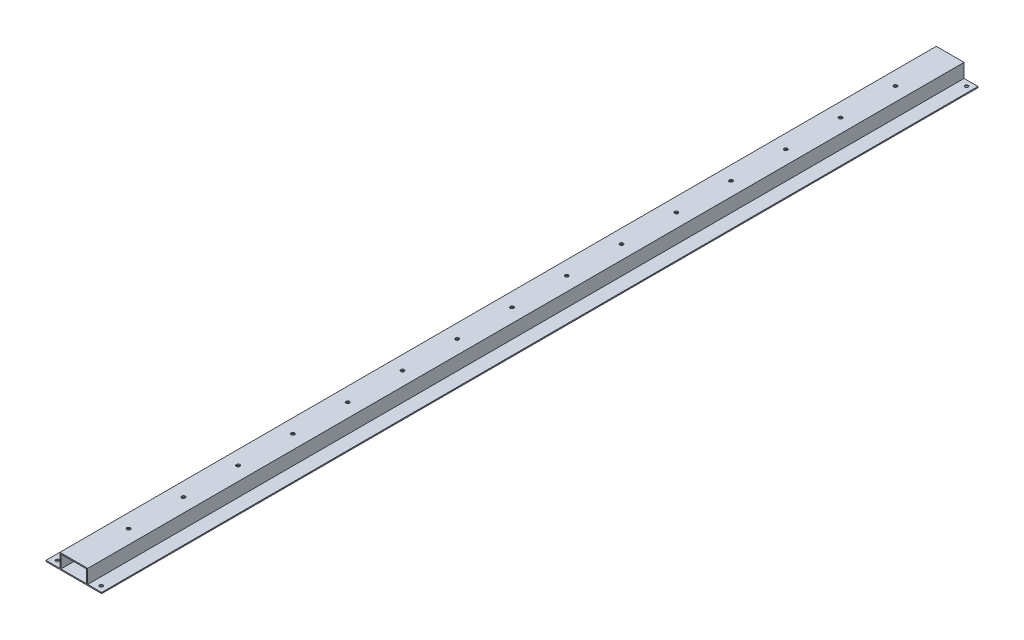
from build123d import *

# Parameters (mm, degrees)
SALIENTE_EXTRUIR1_DEPTH = 400
CROQUIS2_R              = 1.5
CORTAR_EXTRUIR1_DEPTH   = 10
CROQUIS3_R              = 1.5875
CORTAR_EXTRUIR2_DEPTH   = 14.7


with BuildPart() as part:
    # Croquis1 → Saliente-Extruir1 (new body, symmetric)
    with BuildSketch(Plane.XY):
        Polygon((0, 13.7), (12.7, 13.7), (12.7, 1), (25.4, 1), (25.4, 0), (-25.4, 0), (-25.4, 1), (-12.7, 1), (-12.7, 13.7), align=None)
        Polygon((0, 12.7), (-11.7, 12.7), (-11.7, 1), (11.7, 1), (11.7, 12.7), align=None, mode=Mode.SUBTRACT)
    extrude(amount=SALIENTE_EXTRUIR1_DEPTH, both=True)

    # Croquis2 → Cortar-Extruir1 (cut)
    with BuildSketch(Plane.XZ):
        with Locations((-20, 395)):
            Circle(CROQUIS2_R)
        with Locations((20, 395)):
            Circle(CROQUIS2_R)
        with Locations((20, -395)):
            Circle(CROQUIS2_R)
        with Locations((-20, -395)):
            Circle(CROQUIS2_R)
    extrude(amount=-CORTAR_EXTRUIR1_DEPTH, mode=Mode.SUBTRACT)

    # Croquis3 → Cortar-Extruir2 (cut, through all)
    with BuildSketch(Plane.XZ):
        Circle(CROQUIS3_R)
        with Locations((0, 50)):
            Circle(CROQUIS3_R)
        with Locations((0, 100)):
            Circle(CROQUIS3_R)
        with Locations((0, 150)):
            Circle(CROQUIS3_R)
        with Locations((0, 200)):
            Circle(CROQUIS3_R)
        with Locations((0, 250)):
            Circle(CROQUIS3_R)
        with Locations((0, 300)):
            Circle(CROQUIS3_R)
        with Locations((0, 350)):
            Circle(CROQUIS3_R)
        with Locations((0, -50)):
            Circle(CROQUIS3_R)
        with Locations((0, -100)):
            Circle(CROQUIS3_R)
        with Locations((0, -150)):
            Circle(CROQUIS3_R)
        with Locations((0, -200)):
            Circle(CROQUIS3_R)
        with Locations((0, -250)):
            Circle(CROQUIS3_R)
        with Locations((0, -300)):
            Circle(CROQUIS3_R)
        with Locations((0, -350)):
            Circle(CROQUIS3_R)
    extrude(amount=-CORTAR_EXTRUIR2_DEPTH, mode=Mode.SUBTRACT)


solid = part.part
